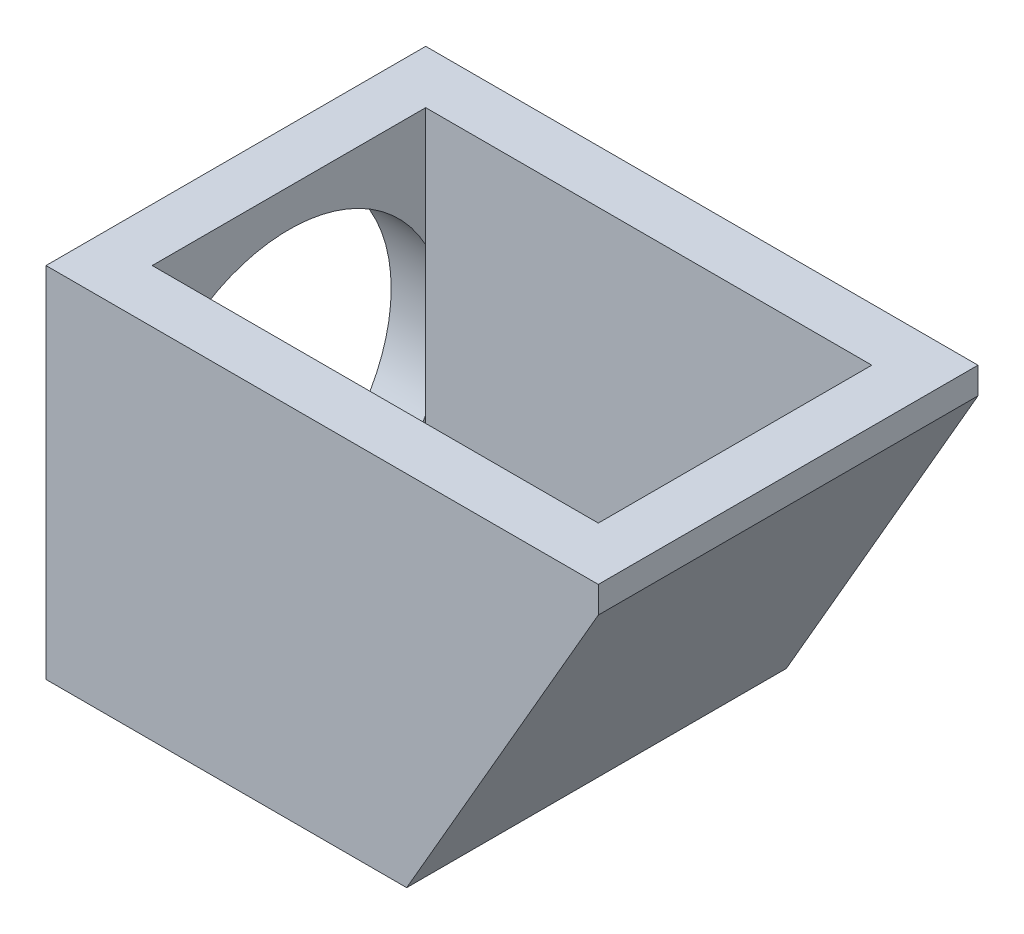
from build123d import *

# Parameters (mm, degrees)
SKETCH1_W           = 20.8
SKETCH1_H           = 14.3
SKETCH1_W_2         = 16.8
SKETCH1_H_2         = 10.3
BOSS_EXTRUDE1_DEPTH = 12.5
SKETCH2_W           = 20.8
SKETCH2_H           = 14.3
BOSS_EXTRUDE2_DEPTH = 1
SKETCH3_R           = 5.85
CUT_EXTRUDE2_DEPTH  = 2
BOSS_EXTRUDE3_DEPTH = 6
CUT_EXTRUDE3_DEPTH  = 14.3


with BuildPart() as part:
    # Sketch1 → Boss-Extrude1 (new body)
    with BuildSketch(Plane(origin=(0, 0, 0), x_dir=(1, 0, 0), z_dir=(0, 1, 0))):
        Rectangle(SKETCH1_W, SKETCH1_H)
        Rectangle(SKETCH1_W_2, SKETCH1_H_2, mode=Mode.SUBTRACT)
    extrude(amount=BOSS_EXTRUDE1_DEPTH)

    # Sketch2 → Boss-Extrude2 (add)
    with BuildSketch(Plane.XZ):
        Rectangle(SKETCH2_W, SKETCH2_H)
    extrude(amount=BOSS_EXTRUDE2_DEPTH)

    # Sketch3 → Cut-Extrude2 (cut)
    with BuildSketch(Plane.ZY.offset(10.4)):
        with Locations((0, 5.25)):
            Circle(SKETCH3_R)
    extrude(amount=-CUT_EXTRUDE2_DEPTH, mode=Mode.SUBTRACT)

    # Sketch4 → Boss-Extrude3 (add, symmetric)
    with BuildSketch(Plane.XY):
        Polygon((8.4, 11.5), (1.760471904, 0), (8.4, 0), align=None)
    extrude(amount=BOSS_EXTRUDE3_DEPTH, both=True)

    # Sketch5 → Cut-Extrude3 (cut)
    with BuildSketch(Plane.XY.offset(7.15)):
        Polygon((10.4, -1), (10.4, 11.5), (3.183121635, -1), align=None)
    extrude(amount=-CUT_EXTRUDE3_DEPTH, mode=Mode.SUBTRACT)


solid = part.part
